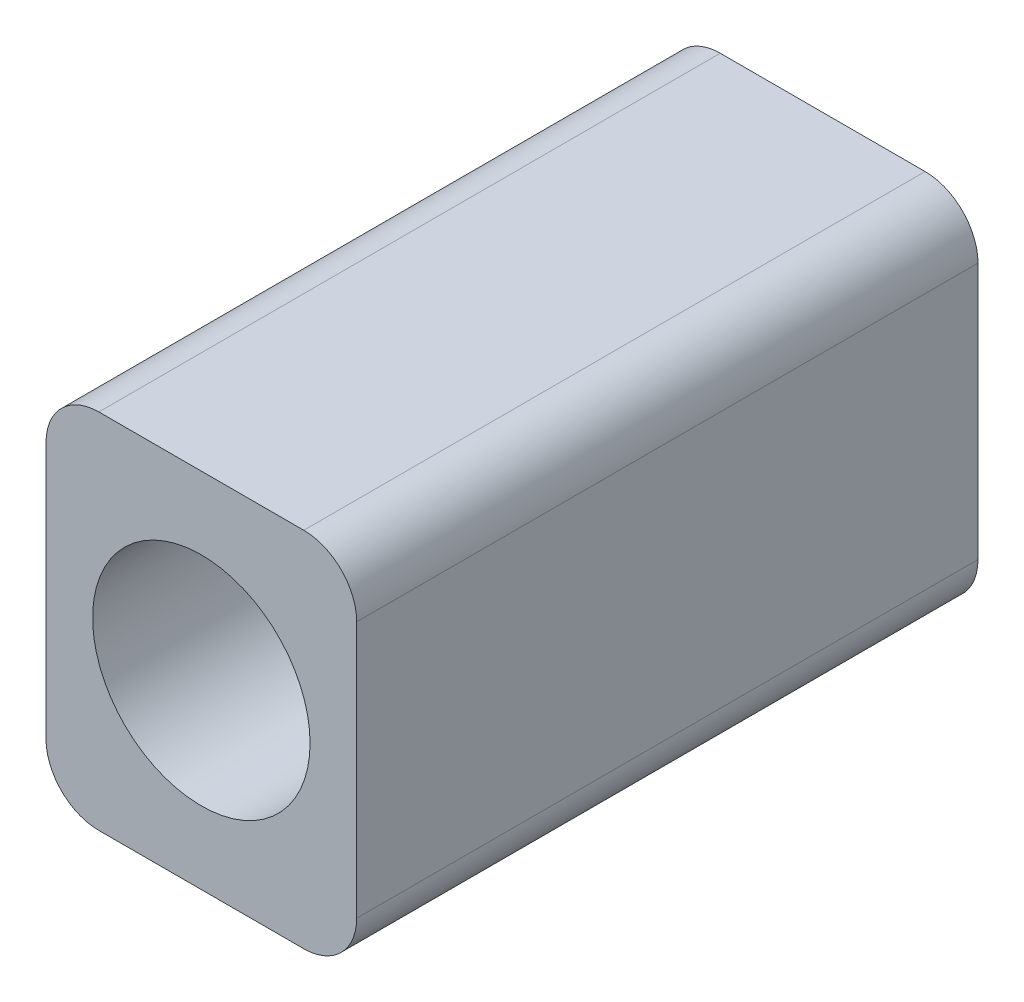
from build123d import *

# Parameters (mm, degrees)
BOSS_EXTRUDE1_DEPTH = 12
SKETCH2_R           = 2.1
CUT_EXTRUDE1_DEPTH  = 8


with BuildPart() as part:
    # Sketch1 → Boss-Extrude1 (new body)
    with BuildSketch(Plane.XY):
        with BuildLine():
            Line((1.021227299, 0), (4.978772701, 0))
            ThreePointArc((4.978772701, 0), (5.700889449, 0.299110551), (6, 1.021227299))
            Line((6, 1.021227299), (6, 5.978772701))
            ThreePointArc((6, 5.978772701), (5.700889449, 6.700889449), (4.978772701, 7))
            Line((4.978772701, 7), (1.021227299, 7))
            ThreePointArc((1.021227299, 7), (0.299110551, 6.700889449), (0, 5.978772701))
            Line((0, 5.978772701), (0, 1.021227299))
            ThreePointArc((0, 1.021227299), (0.299110551, 0.299110551), (1.021227299, 0))
        make_face()
    extrude(amount=BOSS_EXTRUDE1_DEPTH)

    # Sketch2 → Cut-Extrude1 (cut)
    with BuildSketch(Plane.XY.offset(12)):
        with Locations((3, 3.5)):
            Circle(SKETCH2_R)
    extrude(amount=-CUT_EXTRUDE1_DEPTH, mode=Mode.SUBTRACT)


solid = part.part
